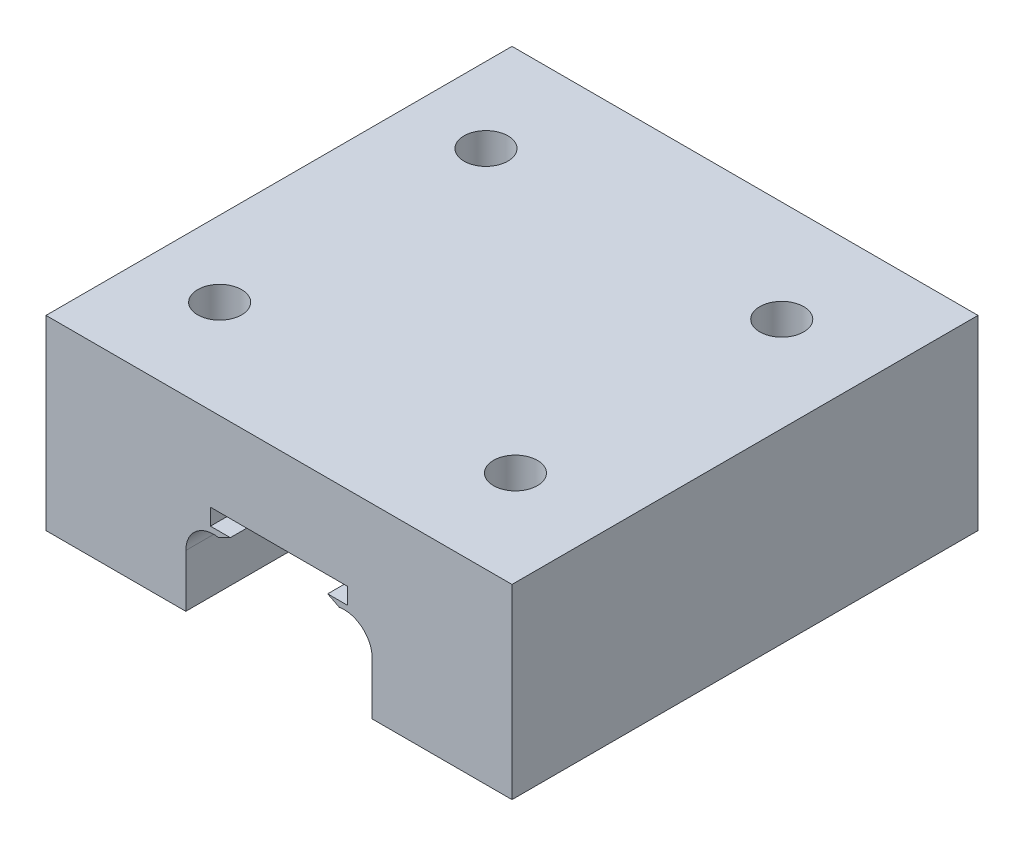
from build123d import *

# Parameters (mm, degrees)
SALIENTE_EXTRUIR1_DEPTH = 50
CROQUIS2_R              = 2.35674785
CORTAR_EXTRUIR1_DEPTH   = 20


with BuildPart() as part:
    # Croquis1 → Saliente-Extruir1 (new body)
    with BuildSketch(Plane.XY):
        with BuildLine():
            Line((-10, 0), (-10, 5.656056356))
            ThreePointArc((-10, 5.656056356), (-8.921539569, 7.959897862), (-6.461542876, 8.607338099))
            Line((-6.461542876, 8.607338099), (-5.221744043, 9.236902282))
            Line((-5.221744043, 9.236902282), (-7.354818693, 9.236902282))
            Line((-7.354818693, 9.236902282), (-7.354818693, 11))
            Line((-7.354818693, 11), (7.354818693, 11))
            Line((7.354818693, 11), (7.354818693, 9.236902282))
            Line((7.354818693, 9.236902282), (5.221744043, 9.236902282))
            Line((5.221744043, 9.236902282), (6.461542876, 8.607338099))
            ThreePointArc((6.461542876, 8.607338099), (8.921539569, 7.959897862), (10, 5.656056356))
            Line((10, 5.656056356), (10, 0))
            Line((10, 0), (25, 0))
            Line((25, 0), (25, 20))
            Line((25, 20), (-25, 20))
            Line((-25, 20), (-25, 0))
            Line((-25, 0), (-10, 0))
        make_face()
    extrude(amount=SALIENTE_EXTRUIR1_DEPTH)

    # Croquis2 → Cortar-Extruir1 (cut)
    with BuildSketch(Plane(origin=(0, 20, 0), x_dir=(1, 0, 0), z_dir=(0, 1, 0))):
        with Locations((14.831866676, -10.889102432)):
            Circle(CROQUIS2_R)
        with Locations((14.831866676, -39.461784116)):
            Circle(CROQUIS2_R)
        with Locations((-16.904414288, -39.461784116)):
            Circle(CROQUIS2_R)
        with Locations((-16.904414288, -10.889102432)):
            Circle(CROQUIS2_R)
    extrude(amount=-CORTAR_EXTRUIR1_DEPTH, mode=Mode.SUBTRACT)


solid = part.part
